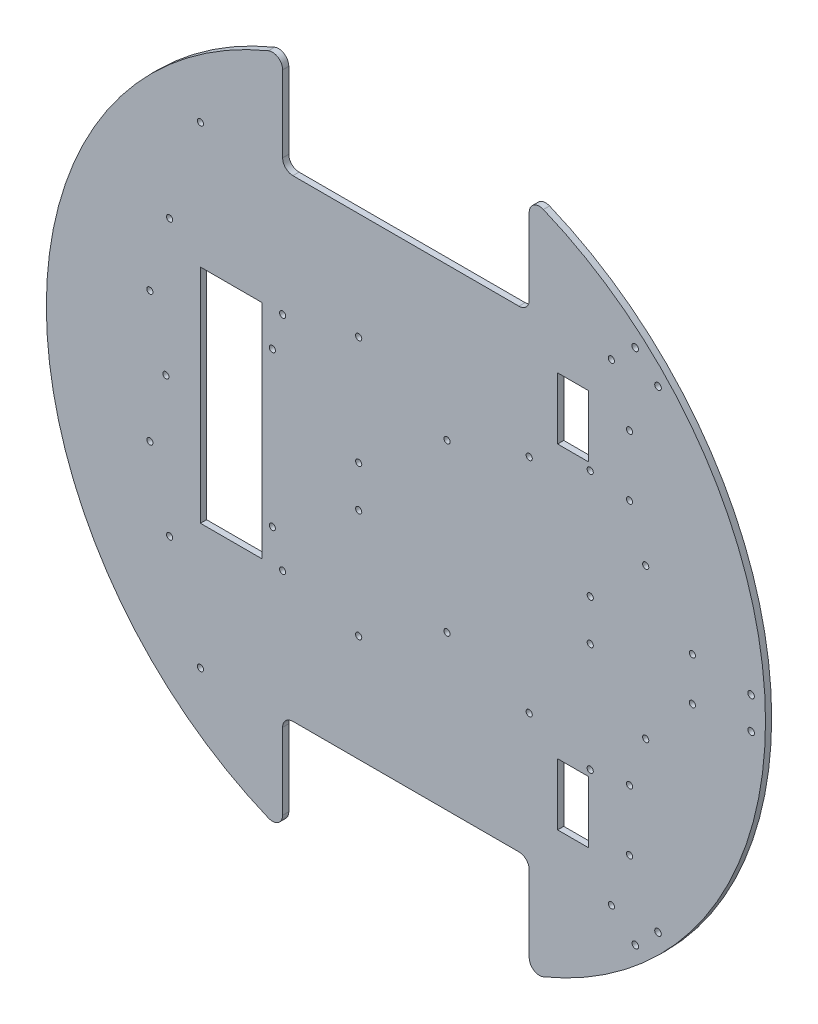
from build123d import *

# Parameters (mm, degrees)
SKETCH_1_R             = 175
EXTRUDE_1_DEPTH        = 3
CUT_EXTRUDE_1_DEPTH    = 3
FILLET_1_R             = 5
FILLET_2_R             = 5
FILLET_3_R             = 5
SKETCH_5_R             = 1.5
CUT_EXTRUDE_4_DEPTH    = 3
SKETCH_6_R             = 1.5
CUT_EXTRUDE_5_DEPTH    = 3
SKETCH_7_W             = 30
SKETCH_7_H             = 108
CUT_EXTRUDE_6_DEPTH    = 3
SKETCH_8_R             = 1.5
CUT_EXTRUDE_7_DEPTH    = 3
SKETCH_9_R             = 1.5
CUT_EXTRUDE_8_DEPTH    = 10
SKETCH_10_R            = 1.6
CUT_EXTRUDE_9_DEPTH    = 10
SKETCH_11_W            = 15
SKETCH_11_H            = 30
CUT_EXTRUDE_10_DEPTH   = 10
SKETCH_12_R            = 1.5
CUT_EXTRUDE_11_DEPTH   = 4
SKETCH_13_R            = 1.5
CUT_EXTRUDE_12_DEPTH   = 4
PATTERN_LINEAR_1_COUNT = 2
PATTERN_LINEAR_1_PITCH = 73
SKETCH_14_R            = 1.5
CUT_EXTRUDE_14_DEPTH   = 4
SKETCH_17_R            = 1.5
CUT_EXTRUDE_15_DEPTH   = 4
SKETCH_18_R            = 1.5
CUT_EXTRUDE_16_DEPTH   = 4


with BuildPart() as part:
    # ｽｹｯﾁ1 → ﾎﾞｽ - 押し出し1 (new body)
    with BuildSketch(Plane.XY):
        Circle(SKETCH_1_R)
    extrude(amount=EXTRUDE_1_DEPTH)

    # ｽｹｯﾁ2 → ｶｯﾄ - 押し出し1 (cut)
    with BuildSketch(Plane.XY.offset(3)):
        with BuildLine():
            Line((-60, 115), (0, 115))
            Line((0, 115), (0, 175))
            ThreePointArc((0, 175), (-30.465194158, 172.327803749), (-60, 164.392822228))
            Line((-60, 164.392822228), (-60, 115))
        make_face()
        with BuildLine():
            Line((0, 175), (0, 115))
            Line((0, 115), (60, 115))
            Line((60, 115), (60, 164.392822228))
            ThreePointArc((60, 164.392822228), (30.465194158, 172.327803749), (0, 175))
        make_face()
        with BuildLine():
            Line((0, -175), (0, -115))
            Line((0, -115), (-60, -115))
            Line((-60, -115), (-60, -164.392822228))
            ThreePointArc((-60, -164.392822228), (-30.465194158, -172.327803749), (0, -175))
        make_face()
        with BuildLine():
            Line((60, -115), (0, -115))
            Line((0, -115), (0, -175))
            ThreePointArc((0, -175), (30.465194158, -172.327803749), (60, -164.392822228))
            Line((60, -164.392822228), (60, -115))
        make_face()
    extrude(amount=-CUT_EXTRUDE_1_DEPTH, mode=Mode.SUBTRACT)

    # ﾌｨﾚｯﾄ1
    fillet_1_edges = [part.edges().sort_by_distance(p)[0] for p in [
        (-60, 164.392822228, 1.5),
    ]]
    fillet(fillet_1_edges, radius=FILLET_1_R)

    # ﾌｨﾚｯﾄ2
    fillet_2_edges = [part.edges().sort_by_distance(p)[0] for p in [
        (-60, 115, 1.5),
        (60, 164.392822228, 1.5),
        (60, 115, 1.5),
    ]]
    fillet(fillet_2_edges, radius=FILLET_2_R)

    # ﾌｨﾚｯﾄ3
    fillet_3_edges = [part.edges().sort_by_distance(p)[0] for p in [
        (-60, -115, 1.5),
        (60, -115, 1.5),
        (60, -164.392822228, 1.5),
        (-60, -164.392822228, 1.5),
    ]]
    fillet(fillet_3_edges, radius=FILLET_3_R)

    # ｽｹｯﾁ5 → ｶｯﾄ - 押し出し4 (cut)
    with BuildSketch(Plane.XY.offset(3)):
        with Locations((-100, -115)):
            Circle(SKETCH_5_R)
        with Locations((100, -115)):
            Circle(SKETCH_5_R)
        with Locations((100, 115)):
            Circle(SKETCH_5_R)
        with Locations((-100, 115)):
            Circle(SKETCH_5_R)
    extrude(amount=-CUT_EXTRUDE_4_DEPTH, mode=Mode.SUBTRACT)

    # ｽｹｯﾁ6 → ｶｯﾄ - 押し出し5 (cut)
    with BuildSketch(Plane.XY.offset(3)):
        with Locations((-60, 54)):
            Circle(SKETCH_6_R)
        with Locations((60, 54)):
            Circle(SKETCH_6_R)
        with Locations((-60, -54)):
            Circle(SKETCH_6_R)
        with Locations((60, -54)):
            Circle(SKETCH_6_R)
    extrude(amount=-CUT_EXTRUDE_5_DEPTH, mode=Mode.SUBTRACT)

    # ｽｹｯﾁ7 → ｶｯﾄ - 押し出し6 (cut)
    with BuildSketch(Plane.XY.offset(3)):
        with Locations((-85, 0)):
            Rectangle(SKETCH_7_W, SKETCH_7_H)
    extrude(amount=-CUT_EXTRUDE_6_DEPTH, mode=Mode.SUBTRACT)

    # ｽｹｯﾁ8 → ｶｯﾄ - 押し出し7 (cut)
    with BuildSketch(Plane.XY.offset(3)):
        with Locations((-115, -67)):
            Circle(SKETCH_8_R)
        with Locations((-116.822468618, 0)):
            Circle(SKETCH_8_R)
        with Locations((-115, 67)):
            Circle(SKETCH_8_R)
    extrude(amount=-CUT_EXTRUDE_7_DEPTH, mode=Mode.SUBTRACT)

    # ｽｹｯﾁ9 → ｶｯﾄ - 押し出し8 (cut)
    with BuildSketch(Plane.XY.offset(3)):
        with Locations((-65, 37)):
            Circle(SKETCH_9_R)
        with Locations((20, 41)):
            Circle(SKETCH_9_R)
        with Locations((-65, -38)):
            Circle(SKETCH_9_R)
        with Locations((20, -40)):
            Circle(SKETCH_9_R)
    extrude(amount=-CUT_EXTRUDE_8_DEPTH, mode=Mode.SUBTRACT)

    # ｽｹｯﾁ10 → ｶｯﾄ - 押し出し9 (cut)
    with BuildSketch(Plane.XY.offset(3)):
        with Locations((111.643659725, -125.921059639)):
            Circle(SKETCH_10_R)
        with Locations((122.679794489, -115.037952538)):
            Circle(SKETCH_10_R)
        with Locations((168, 7.75)):
            Circle(SKETCH_10_R)
        with Locations((168, -7.75)):
            Circle(SKETCH_10_R)
        with Locations((111.56768007, 125.844011632)):
            Circle(SKETCH_10_R)
        with Locations((122.679794489, 115.037952538)):
            Circle(SKETCH_10_R)
    extrude(amount=-CUT_EXTRUDE_9_DEPTH, mode=Mode.SUBTRACT)

    # ｽｹｯﾁ11 → ｶｯﾄ - 押し出し10 (cut)
    with BuildSketch(Plane.XY.offset(3)):
        with Locations((81.317279836, 81.317279836)):
            Rectangle(SKETCH_11_W, SKETCH_11_H)
        with Locations((81.317279836, -81.317279836)):
            Rectangle(SKETCH_11_W, SKETCH_11_H)
    extrude(amount=-CUT_EXTRUDE_10_DEPTH, mode=Mode.SUBTRACT)

    # ｽｹｯﾁ12 → ｶｯﾄ - 押し出し11 (cut, through all)
    with BuildSketch(Plane.XY.offset(3)):
        with Locations((139.4, 10.5)):
            Circle(SKETCH_12_R)
        with Locations((139.4, -10.5)):
            Circle(SKETCH_12_R)
    extrude(amount=-CUT_EXTRUDE_11_DEPTH, mode=Mode.SUBTRACT)

    # ｽｹｯﾁ13 → ｶｯﾄ - 押し出し12 (cut, through all)
    with BuildSketch(Plane.XY.offset(3)):
        with Locations((89.692125231, 10)):
            Circle(SKETCH_13_R)
        with Locations((89.692125231, 63)):
            Circle(SKETCH_13_R)
        with Locations((-22.988418993, 63)):
            Circle(SKETCH_13_R)
        with Locations((-22.988418993, 10)):
            Circle(SKETCH_13_R)
        with Locations((116.692125231, 36.5)):
            Circle(SKETCH_13_R)
    cut_extrude_12 = extrude(amount=-CUT_EXTRUDE_12_DEPTH, mode=Mode.SUBTRACT)

    # 直線ﾊﾟﾀｰﾝ1: ｶｯﾄ - 押し出し12 ×2
    with Locations(*[(0, -i * PATTERN_LINEAR_1_PITCH, 0) for i in range(1, PATTERN_LINEAR_1_COUNT)]):
        add(cut_extrude_12, mode=Mode.SUBTRACT)

    # ｽｹｯﾁ14 → ｶｯﾄ - 押し出し14 (cut, through all)
    with BuildSketch(Plane.XY.offset(3)):
        with Locations((108.817279836, 89.5)):
            Circle(SKETCH_14_R)
        with Locations((108.817279836, 60)):
            Circle(SKETCH_14_R)
    extrude(amount=-CUT_EXTRUDE_14_DEPTH, mode=Mode.SUBTRACT)

    # ｽｹｯﾁ17 → ｶｯﾄ - 押し出し15 (cut, through all)
    with BuildSketch(Plane.XY.offset(3)):
        with Locations((108.817279836, -60)):
            Circle(SKETCH_17_R)
        with Locations((108.817279836, -89.5)):
            Circle(SKETCH_17_R)
    extrude(amount=-CUT_EXTRUDE_15_DEPTH, mode=Mode.SUBTRACT)

    # ｽｹｯﾁ18 → ｶｯﾄ - 押し出し16 (cut, through all)
    with BuildSketch(Plane.XY.offset(3)):
        with Locations((-124.610636376, 31.75)):
            Circle(SKETCH_18_R)
        with Locations((-124.610636376, -31.75)):
            Circle(SKETCH_18_R)
    extrude(amount=-CUT_EXTRUDE_16_DEPTH, mode=Mode.SUBTRACT)


solid = part.part
